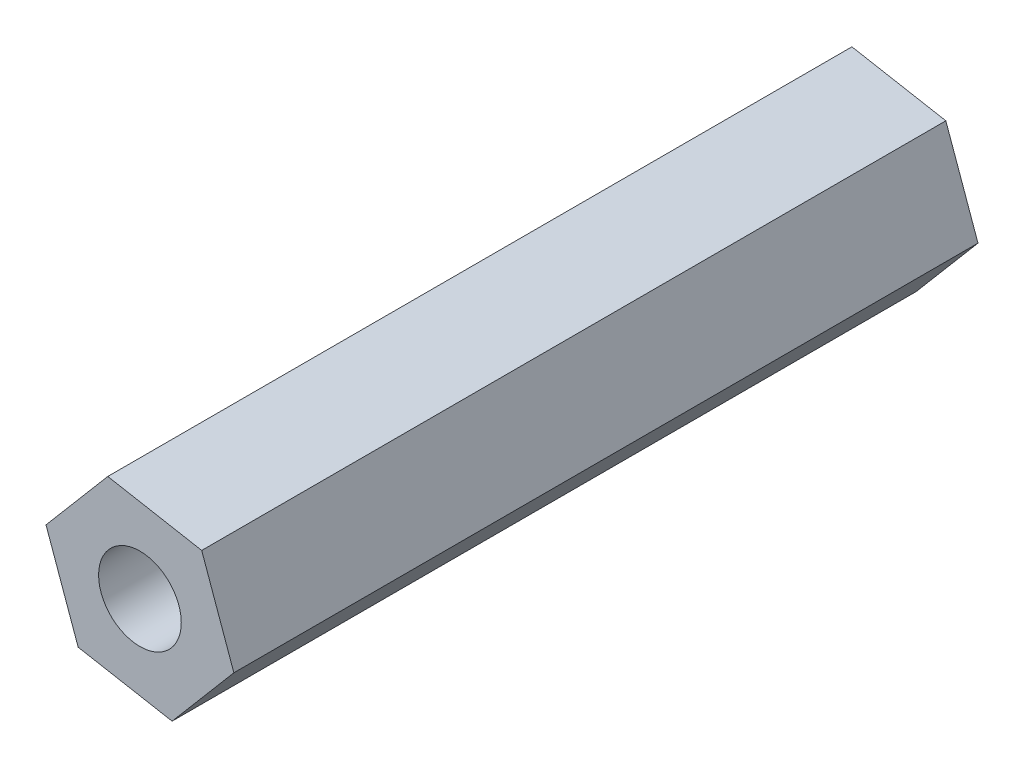
from build123d import *

# Parameters (mm, degrees)
RESSALTO_EXTRUS_O1_DEPTH = 27
ESBO_O4_R                = 1.5
CORTE_EXTRUS_O2_DEPTH    = 40


with BuildPart() as part:
    # Esboço1 → Ressalto-extrusão1 (new body)
    with BuildSketch(Plane.XY):
        Polygon((12.933175524, -4.143885809), (9.525050306, -3.523658029), (7.283854683, -6.165067156), (8.450784277, -9.426704064), (11.858909495, -10.046931845), (14.100105118, -7.405522718), align=None)
    extrude(amount=RESSALTO_EXTRUS_O1_DEPTH)

    # Esboço4 → Corte-extrusão2 (cut)
    with BuildSketch(Plane(origin=(0, 0, 0), x_dir=(-1, 0, 0), z_dir=(0, 0, -1))):
        with Locations((-10.691979901, -6.785294937)):
            Circle(ESBO_O4_R)
    extrude(amount=-CORTE_EXTRUS_O2_DEPTH, mode=Mode.SUBTRACT)


solid = part.part
